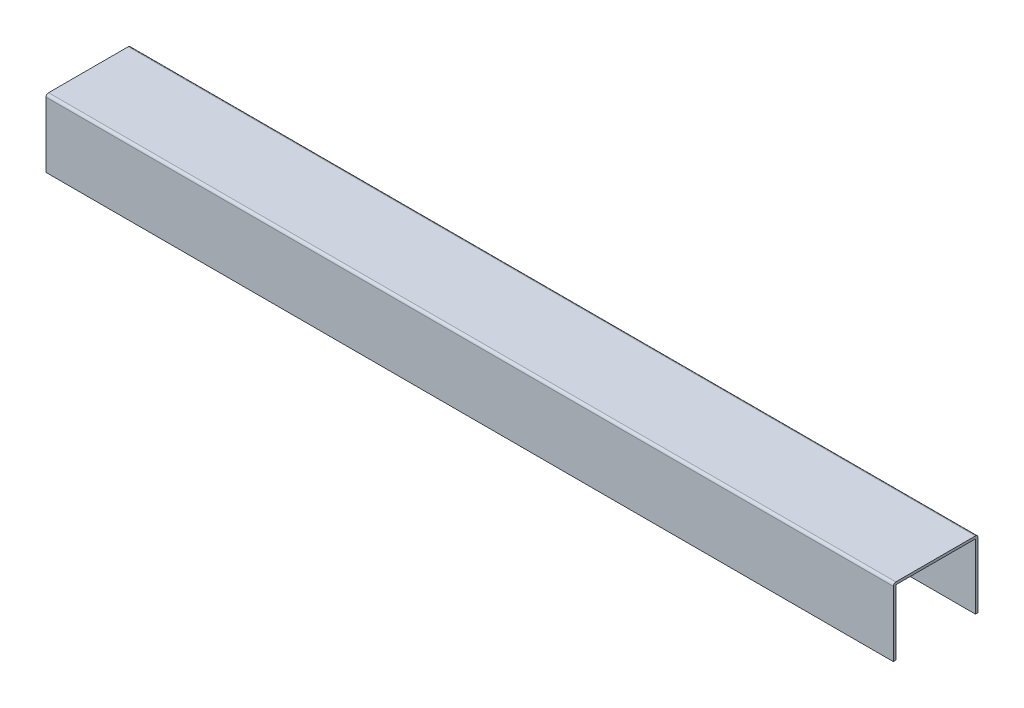
from build123d import *

# Parameters (mm, degrees)
SKETCH_1_W          = 94
SKETCH_1_H          = 94
EXTRUDE_1_DEPTH     = 1000
SKETCH_2_W          = 1000
SKETCH_2_H          = 20
CUT_EXTRUDE_1_DEPTH = 101


with BuildPart() as part:
    # Эскиз1 → Вытянуть-Тонкостенный1 (new body)
    with BuildSketch(Plane(origin=(0, 0, 0), x_dir=(0, 0, -1), z_dir=(1, 0, 0))):
        with BuildLine():
            Line((0, 97), (0, 3))
            ThreePointArc((0, 3), (0.878679656, 0.878679656), (3, 0))
            Line((3, 0), (97, 0))
            ThreePointArc((97, 0), (99.121320344, 0.878679656), (100, 3))
            Line((100, 3), (100, 97))
            ThreePointArc((100, 97), (99.121320344, 99.121320344), (97, 100))
            Line((97, 100), (3, 100))
            ThreePointArc((3, 100), (0.878679656, 99.121320344), (0, 97))
        make_face()
        with Locations((50, 50)):
            Rectangle(SKETCH_1_W, SKETCH_1_H, mode=Mode.SUBTRACT)
    extrude(amount=EXTRUDE_1_DEPTH)

    # Эскиз2 → Вырез-Вытянуть1 (cut, through all)
    with BuildSketch(Plane(origin=(0, 0, -100), x_dir=(-1, 0, 0), z_dir=(0, 0, -1))):
        with Locations((-500, 10)):
            Rectangle(SKETCH_2_W, SKETCH_2_H)
    extrude(amount=-CUT_EXTRUDE_1_DEPTH, mode=Mode.SUBTRACT)


solid = part.part
